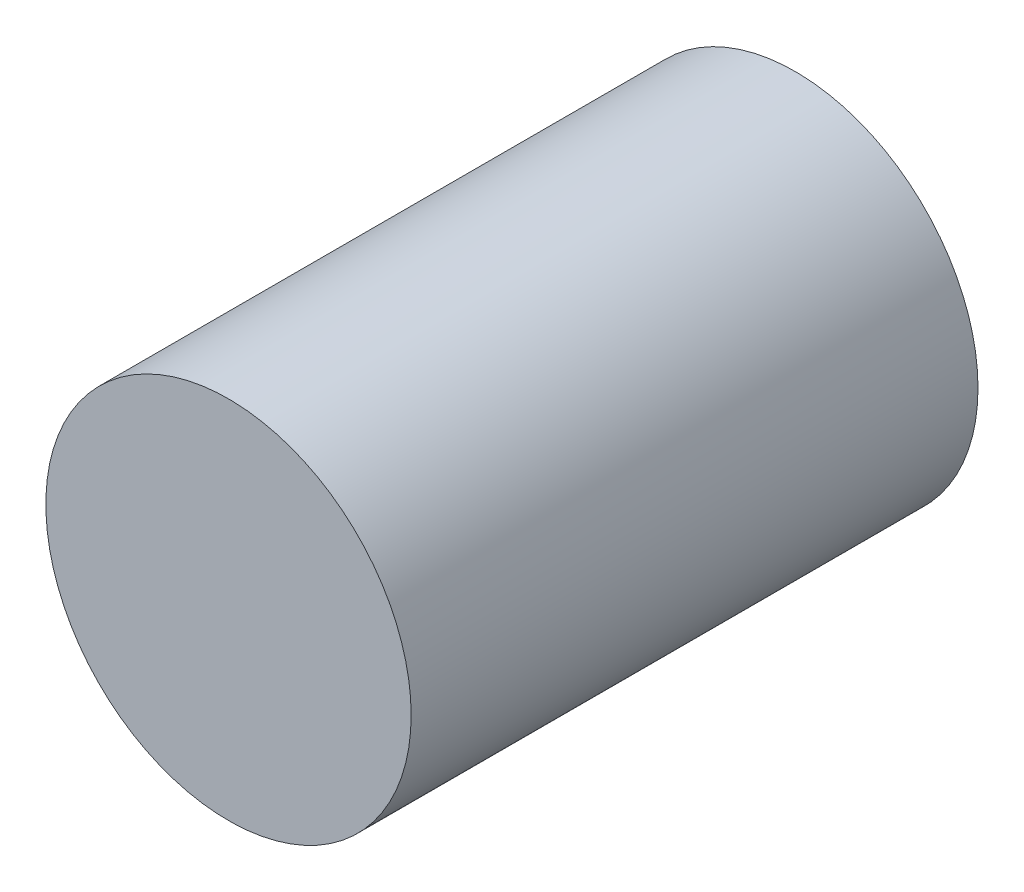
from build123d import *

# Parameters (mm, degrees)
SKETCH1_R           = 5.8
BOSS_EXTRUDE1_DEPTH = 18
SKETCH2_R           = 4
CUT_EXTRUDE1_DEPTH  = 12


with BuildPart() as part:
    # Sketch1 → Boss-Extrude1 (new body)
    with BuildSketch(Plane.XY):
        Circle(SKETCH1_R)
    extrude(amount=-BOSS_EXTRUDE1_DEPTH)

    # Sketch2 → Cut-Extrude1 (cut)
    with BuildSketch(Plane(origin=(0, 0, -18), x_dir=(-1, 0, 0), z_dir=(0, 0, -1))):
        Circle(SKETCH2_R)
    extrude(amount=-CUT_EXTRUDE1_DEPTH, mode=Mode.SUBTRACT)


solid = part.part
